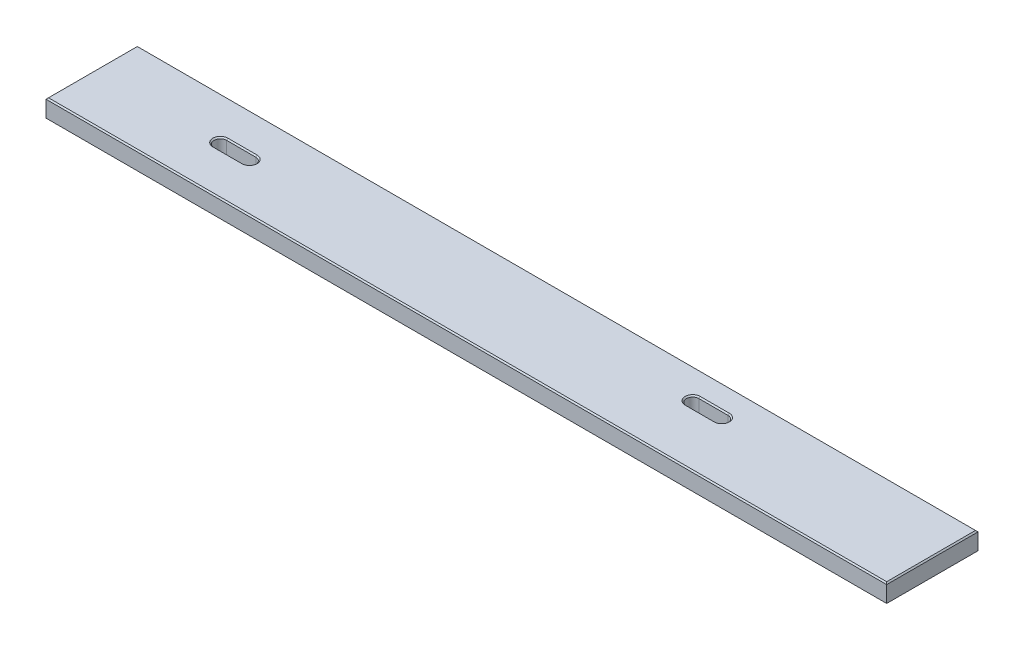
from build123d import *

# Parameters (mm, degrees)
SKETCH1_W           = 1695.45
SKETCH1_H           = 184.15
BOSS_EXTRUDE1_DEPTH = 38.1
CHAMFER1_SIZE       = 2.54
CHAMFER2_SIZE       = 2.54
SKETCH2_R           = 19.05
CUT_EXTRUDE1_DEPTH  = 3.175


with BuildPart() as part:
    # Sketch1 → Boss-Extrude1 (new body)
    with BuildSketch(Plane(origin=(0, 0, 0), x_dir=(1, 0, 0), z_dir=(0, 1, 0))):
        with Locations((847.725, 92.075)):
            Rectangle(SKETCH1_W, SKETCH1_H)
        with BuildLine():
            Line((1240.0153, 110.16615), (1181.2651, 110.16615))
            ThreePointArc((1181.2651, 110.16615), (1168.5651, 122.86615), (1181.2651, 135.56615))
            Line((1181.2651, 135.56615), (1240.0153, 135.56615))
            ThreePointArc((1240.0153, 135.56615), (1252.7153, 122.86615), (1240.0153, 110.16615))
        make_face(mode=Mode.SUBTRACT)
        with BuildLine():
            Line((254, 110.31855), (312.7502, 110.31855))
            ThreePointArc((312.7502, 110.31855), (325.4502, 97.61855), (312.7502, 84.91855))
            Line((312.7502, 84.91855), (254, 84.91855))
            ThreePointArc((254, 84.91855), (241.3, 97.61855), (254, 110.31855))
        make_face(mode=Mode.SUBTRACT)
    extrude(amount=BOSS_EXTRUDE1_DEPTH)

    # Chamfer1
    chamfer1_edges = [part.edges().sort_by_distance(p)[0] for p in [
        (1695.45, 38.1, -92.075),
        (1252.7153, 38.1, -122.86615),
        (847.725, 38.1, -184.15),
        (1210.6402, 38.1, -135.56615),
        (1168.5651, 38.1, -122.86615),
        (1210.6402, 38.1, -110.16615),
        (325.4502, 38.1, -97.61855),
        (283.3751, 38.1, -110.31855),
        (241.3, 38.1, -97.61855),
        (283.3751, 38.1, -84.91855),
        (0, 38.1, -92.075),
        (847.725, 38.1, 0),
    ]]
    chamfer(chamfer1_edges, length=CHAMFER1_SIZE)

    # Chamfer2
    chamfer2_edges = [part.edges().sort_by_distance(p)[0] for p in [
        (1252.7153, 0, -122.86615),
        (1210.6402, 0, -135.56615),
        (1168.5651, 0, -122.86615),
        (1210.6402, 0, -110.16615),
        (325.4502, 0, -97.61855),
        (283.3751, 0, -110.31855),
        (241.3, 0, -97.61855),
        (283.3751, 0, -84.91855),
        (847.725, 0, -184.15),
        (1695.45, 0, -92.075),
        (847.725, 0, 0),
        (0, 0, -92.075),
    ]]
    chamfer(chamfer2_edges, length=CHAMFER2_SIZE)

    # Sketch2 → Cut-Extrude1 (cut)
    with BuildSketch(Plane(origin=(0, 0, 0), x_dir=(1, 0, 0), z_dir=(0, 1, 0))):
        with Locations((283.3751, 97.61855)):
            Circle(SKETCH2_R)
        with Locations((1210.6402, 122.86615)):
            Circle(SKETCH2_R)
    extrude(amount=CUT_EXTRUDE1_DEPTH, mode=Mode.SUBTRACT)


solid = part.part
